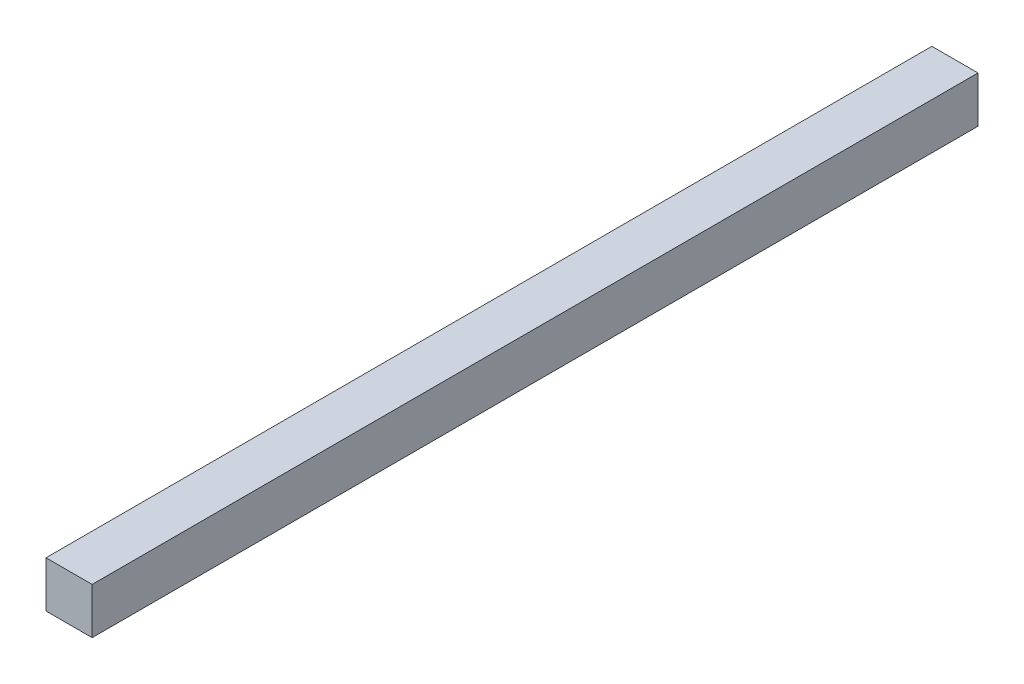
from build123d import *

# Parameters (mm, degrees)
SKETCH1_W           = 5
SKETCH1_H           = 5
BOSS_EXTRUDE1_DEPTH = 96


with BuildPart() as part:
    # Sketch1 → Boss-Extrude1 (new body)
    with BuildSketch(Plane.XY):
        with Locations((2.5, 2.5)):
            Rectangle(SKETCH1_W, SKETCH1_H)
    extrude(amount=BOSS_EXTRUDE1_DEPTH)


solid = part.part
